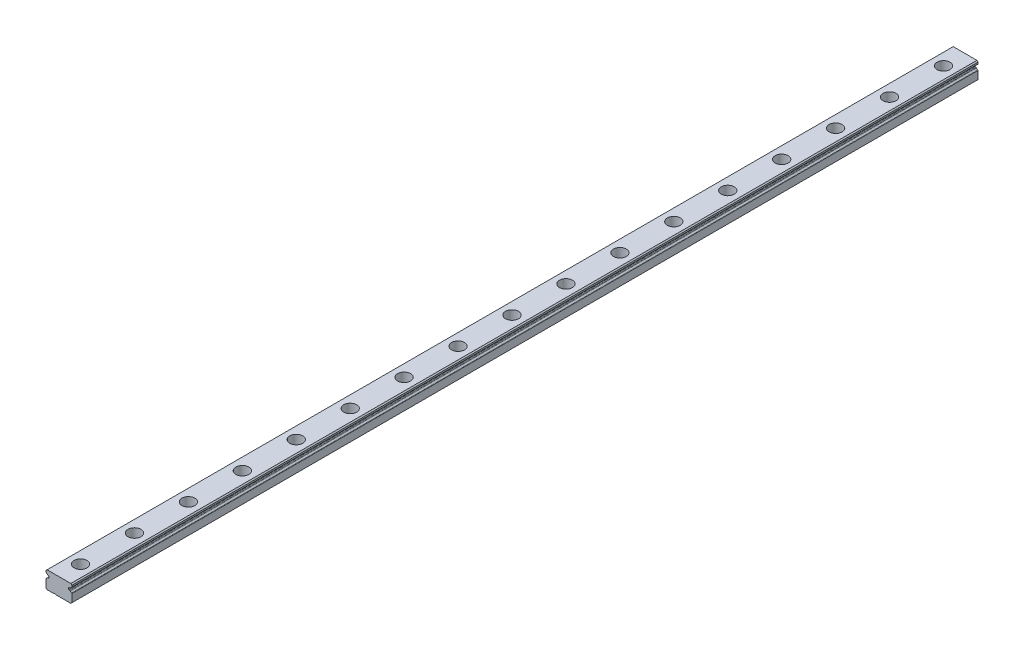
from build123d import *

# Parameters (mm, degrees)
BOSS_EXTRUDE1_DEPTH = 420
SKETCH2_R           = 1.75
CUT_EXTRUDE1_DEPTH  = 421.119030714
SKETCH2_3_R         = 3
CUT_EXTRUDE2_DEPTH  = 4.5


with BuildPart() as part:
    # Sketch1 → Boss-Extrude1 (new body)
    with BuildSketch(Plane.XY):
        with BuildLine():
            Line((5.5, -7.999998), (6, -7.499998))
            Line((6, -7.499998), (6, -3.85787958))
            ThreePointArc((6, -3.85787958), (5.9576137, -3.718608076), (5.844827586, -3.626562203))
            ThreePointArc((5.844827586, -3.626562203), (5.51524529, -3.424071402), (5.267205011, -3.12724985))
            ThreePointArc((5.267205011, -3.12724985), (5.185241933, -3.042985123), (5.073828324, -3.005495145))
            Line((5.073828324, -3.005495145), (4.728211064, -2.975257553))
            ThreePointArc((4.728211064, -2.975257553), (4.565680666, -2.89510643), (4.5, -2.726208878))
            Line((4.5, -2.726208878), (4.5, -2.273787121))
            ThreePointArc((4.5, -2.273787121), (4.565680666, -2.10488957), (4.728211064, -2.024738447))
            Line((4.728211064, -2.024738447), (5.09477657, -1.992668121))
            ThreePointArc((5.09477657, -1.992668121), (5.203244499, -1.957004425), (5.284541491, -1.876829678))
            ThreePointArc((5.284541491, -1.876829678), (5.527906161, -1.597614221), (5.844827586, -1.405915383))
            ThreePointArc((5.844827586, -1.405915383), (5.9576137, -1.31386951), (6, -1.174598006))
            Line((6, -1.174598006), (6, -0.5))
            Line((6, -0.5), (5.5, 0))
            Line((5.5, 0), (-5.5, 0))
            Line((-5.5, 0), (-6, -0.5))
            Line((-6, -0.5), (-6, -1.174598006))
            ThreePointArc((-6, -1.174598006), (-5.9576137, -1.31386951), (-5.844827586, -1.405915383))
            ThreePointArc((-5.844827586, -1.405915383), (-5.527906161, -1.597614221), (-5.284541491, -1.876829678))
            ThreePointArc((-5.284541491, -1.876829678), (-5.203244499, -1.957004425), (-5.09477657, -1.992668121))
            Line((-5.09477657, -1.992668121), (-4.728211064, -2.024738447))
            ThreePointArc((-4.728211064, -2.024738447), (-4.565680666, -2.10488957), (-4.5, -2.273787121))
            Line((-4.5, -2.273787121), (-4.5, -2.726208878))
            ThreePointArc((-4.5, -2.726208878), (-4.565680666, -2.89510643), (-4.728211064, -2.975257553))
            Line((-4.728211064, -2.975257553), (-5.073828324, -3.005495145))
            ThreePointArc((-5.073828324, -3.005495145), (-5.185241932, -3.042985123), (-5.267205011, -3.12724985))
            ThreePointArc((-5.267205011, -3.12724985), (-5.51524529, -3.424071402), (-5.844827586, -3.626562203))
            ThreePointArc((-5.844827586, -3.626562203), (-5.9576137, -3.718608076), (-6, -3.85787958))
            Line((-6, -3.85787958), (-6, -7.499998))
            Line((-6, -7.499998), (-5.5, -7.999998))
            Line((-5.5, -7.999998), (-2.4, -7.999998))
            ThreePointArc((-2.4, -7.999998), (-2, -7.799998), (-1.6, -7.999998))
            Line((-1.6, -7.999998), (5.5, -7.999998))
        make_face()
    extrude(amount=BOSS_EXTRUDE1_DEPTH)

    # Sketch2 → Cut-Extrude1 (cut, through all)
    with BuildSketch(Plane(origin=(0, 0, 0), x_dir=(1, 0, 0), z_dir=(0, 1, 0))):
        with Locations((0, -10)):
            Circle(SKETCH2_R)
        with Locations((0, -35)):
            Circle(SKETCH2_R)
        with Locations((0, -60)):
            Circle(SKETCH2_R)
        with Locations((0, -85)):
            Circle(SKETCH2_R)
        with Locations((0, -110)):
            Circle(SKETCH2_R)
        with Locations((0, -135)):
            Circle(SKETCH2_R)
        with Locations((0, -160)):
            Circle(SKETCH2_R)
        with Locations((0, -185)):
            Circle(SKETCH2_R)
        with Locations((0, -210)):
            Circle(SKETCH2_R)
        with Locations((0, -235)):
            Circle(SKETCH2_R)
        with Locations((0, -260)):
            Circle(SKETCH2_R)
        with Locations((0, -285)):
            Circle(SKETCH2_R)
        with Locations((0, -310)):
            Circle(SKETCH2_R)
        with Locations((0, -335)):
            Circle(SKETCH2_R)
        with Locations((0, -360)):
            Circle(SKETCH2_R)
        with Locations((0, -385)):
            Circle(SKETCH2_R)
        with Locations((0, -410)):
            Circle(SKETCH2_R)
    extrude(amount=-CUT_EXTRUDE1_DEPTH, mode=Mode.SUBTRACT)

    # Sketch2_3 → Cut-Extrude2 (cut)
    with BuildSketch(Plane(origin=(0, 0, 0), x_dir=(1, 0, 0), z_dir=(0, 1, 0))):
        with Locations((0, -10)):
            Circle(SKETCH2_3_R)
        with Locations((0, -35)):
            Circle(SKETCH2_3_R)
        with Locations((0, -60)):
            Circle(SKETCH2_3_R)
        with Locations((0, -85)):
            Circle(SKETCH2_3_R)
        with Locations((0, -110)):
            Circle(SKETCH2_3_R)
        with Locations((0, -135)):
            Circle(SKETCH2_3_R)
        with Locations((0, -160)):
            Circle(SKETCH2_3_R)
        with Locations((0, -185)):
            Circle(SKETCH2_3_R)
        with Locations((0, -210)):
            Circle(SKETCH2_3_R)
        with Locations((0, -235)):
            Circle(SKETCH2_3_R)
        with Locations((0, -260)):
            Circle(SKETCH2_3_R)
        with Locations((0, -285)):
            Circle(SKETCH2_3_R)
        with Locations((0, -310)):
            Circle(SKETCH2_3_R)
        with Locations((0, -335)):
            Circle(SKETCH2_3_R)
        with Locations((0, -360)):
            Circle(SKETCH2_3_R)
        with Locations((0, -385)):
            Circle(SKETCH2_3_R)
        with Locations((0, -410)):
            Circle(SKETCH2_3_R)
    extrude(amount=-CUT_EXTRUDE2_DEPTH, mode=Mode.SUBTRACT)


solid = part.part
